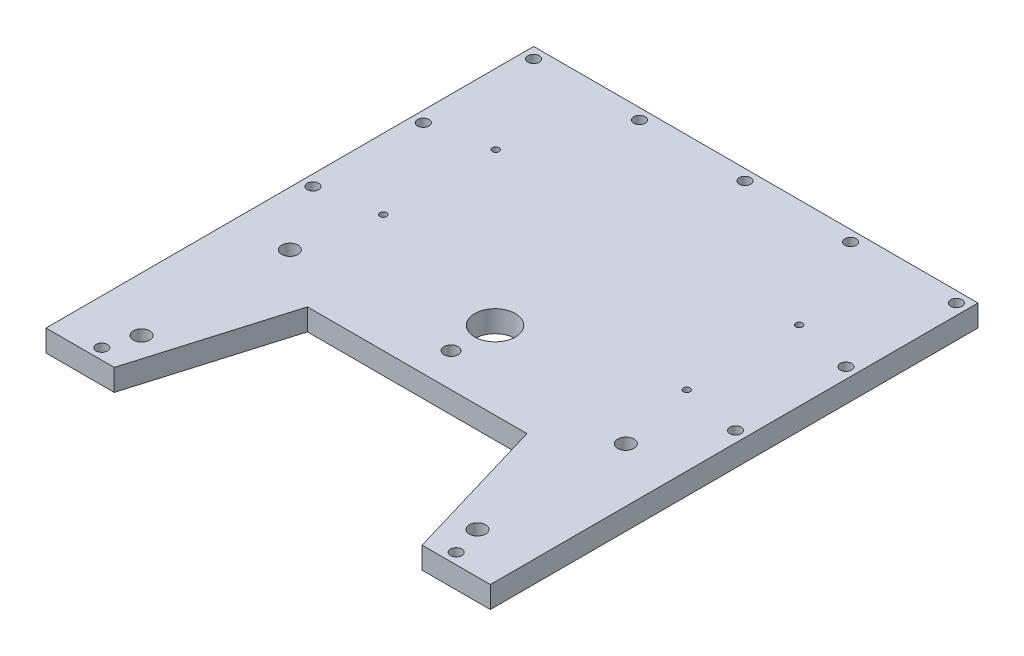
from build123d import *

# Parameters (mm, degrees)
BOSS_EXTRUDE3_DEPTH = 8
SKETCH3_R           = 2.1
CUT_EXTRUDE2_DEPTH  = 10
CUT_EXTRUDE3_REACH  = 10
SKETCH5_R           = 3
SKETCH5_R_2         = 7.5
SKETCH5_R_3         = 2.6
CUT_EXTRUDE4_REACH  = 10
SKETCH6_R           = 1.25


with BuildPart() as part:
    # Sketch1 → Boss-Extrude3 (new body)
    with BuildSketch(Plane(origin=(0, 0, 0), x_dir=(1, 0, 0), z_dir=(0, 1, 0))):
        Polygon((40.5, -35), (56.816666667, -90), (82, -90), (82, 90), (-82, 90), (-82, -90), (-56.816666667, -90), (-40.5, -35), align=None)
    extrude(amount=BOSS_EXTRUDE3_DEPTH)

    # Sketch3 → Cut-Extrude2 (cut)
    with BuildSketch(Plane(origin=(-73, 8, 0), x_dir=(0, 0, 1), z_dir=(0, 1, 0))):
        with Locations((-45.25, -5)):
            Circle(SKETCH3_R)
        with Locations((-86, -5)):
            Circle(SKETCH3_R)
        with Locations((-86, 34)):
            Circle(SKETCH3_R)
        with Locations((-86, 73)):
            Circle(SKETCH3_R)
        with Locations((-86, 112)):
            Circle(SKETCH3_R)
        with Locations((-86, 151)):
            Circle(SKETCH3_R)
        with Locations((-4.5, -5)):
            Circle(SKETCH3_R)
        with Locations((-4.5, 151)):
            Circle(SKETCH3_R)
        with Locations((-45.25, 151)):
            Circle(SKETCH3_R)
        with Locations((86, 7.59)):
            Circle(SKETCH3_R)
        with Locations((86, 138.41)):
            Circle(SKETCH3_R)
    extrude(amount=-CUT_EXTRUDE2_DEPTH, mode=Mode.SUBTRACT)

    # Sketch5 → Cut-Extrude3 (cut, up to next)
    with BuildSketch(Plane(origin=(0, 8, 0), x_dir=(1, 0, 0), z_dir=(0, 1, 0)), mode=Mode.PRIVATE) as cut_extrude3_sk1:
        with Locations((62, -74.75)):
            Circle(SKETCH5_R)
    cut_extrude3_tool1 = extrude(cut_extrude3_sk1.sketch, amount=-CUT_EXTRUDE3_REACH, mode=Mode.PRIVATE) & part.part
    add(cut_extrude3_tool1.solids().sort_by_distance((62, 8, 74.75))[0], mode=Mode.SUBTRACT)
    # Sketch5 → Cut-Extrude3 (cut, up to next)
    with BuildSketch(Plane(origin=(0, 8, 0), x_dir=(1, 0, 0), z_dir=(0, 1, 0)), mode=Mode.PRIVATE) as cut_extrude3_sk2:
        with Locations((62, -19.99)):
            Circle(SKETCH5_R)
    cut_extrude3_tool2 = extrude(cut_extrude3_sk2.sketch, amount=-CUT_EXTRUDE3_REACH, mode=Mode.PRIVATE) & part.part
    add(cut_extrude3_tool2.solids().sort_by_distance((62, 8, 19.99))[0], mode=Mode.SUBTRACT)
    # Sketch5 → Cut-Extrude3 (cut, up to next)
    with BuildSketch(Plane(origin=(0, 8, 0), x_dir=(1, 0, 0), z_dir=(0, 1, 0)), mode=Mode.PRIVATE) as cut_extrude3_sk3:
        with Locations((-62, -74.75)):
            Circle(SKETCH5_R)
    cut_extrude3_tool3 = extrude(cut_extrude3_sk3.sketch, amount=-CUT_EXTRUDE3_REACH, mode=Mode.PRIVATE) & part.part
    add(cut_extrude3_tool3.solids().sort_by_distance((-62, 8, 74.75))[0], mode=Mode.SUBTRACT)
    # Sketch5 → Cut-Extrude3 (cut, up to next)
    with BuildSketch(Plane(origin=(0, 8, 0), x_dir=(1, 0, 0), z_dir=(0, 1, 0)), mode=Mode.PRIVATE) as cut_extrude3_sk4:
        with Locations((-62, -19.99)):
            Circle(SKETCH5_R)
    cut_extrude3_tool4 = extrude(cut_extrude3_sk4.sketch, amount=-CUT_EXTRUDE3_REACH, mode=Mode.PRIVATE) & part.part
    add(cut_extrude3_tool4.solids().sort_by_distance((-62, 8, 19.99))[0], mode=Mode.SUBTRACT)
    # Sketch5 → Cut-Extrude3 (cut, up to next)
    with BuildSketch(Plane(origin=(0, 8, 0), x_dir=(1, 0, 0), z_dir=(0, 1, 0)), mode=Mode.PRIVATE) as cut_extrude3_sk5:
        with Locations((0, -6.25)):
            Circle(SKETCH5_R_2)
    cut_extrude3_tool5 = extrude(cut_extrude3_sk5.sketch, amount=-CUT_EXTRUDE3_REACH, mode=Mode.PRIVATE) & part.part
    add(cut_extrude3_tool5.solids().sort_by_distance((0, 8, 6.25))[0], mode=Mode.SUBTRACT)
    # Sketch5 → Cut-Extrude3 (cut, up to next)
    with BuildSketch(Plane(origin=(0, 8, 0), x_dir=(1, 0, 0), z_dir=(0, 1, 0)), mode=Mode.PRIVATE) as cut_extrude3_sk6:
        with Locations((0, -22.5)):
            Circle(SKETCH5_R_3)
    cut_extrude3_tool6 = extrude(cut_extrude3_sk6.sketch, amount=-CUT_EXTRUDE3_REACH, mode=Mode.PRIVATE) & part.part
    add(cut_extrude3_tool6.solids().sort_by_distance((0, 8, 22.5))[0], mode=Mode.SUBTRACT)

    # Sketch6 → Cut-Extrude4 (cut, up to next)
    with BuildSketch(Plane(origin=(0, 8, 0), x_dir=(1, 0, 0), z_dir=(0, 1, 0)), mode=Mode.PRIVATE) as cut_extrude4_sk1:
        with Locations((-56, 8.5)):
            Circle(SKETCH6_R)
    cut_extrude4_tool1 = extrude(cut_extrude4_sk1.sketch, amount=-CUT_EXTRUDE4_REACH, mode=Mode.PRIVATE) & part.part
    add(cut_extrude4_tool1.solids().sort_by_distance((-56, 8, -8.5))[0], mode=Mode.SUBTRACT)
    # Sketch6 → Cut-Extrude4 (cut, up to next)
    with BuildSketch(Plane(origin=(0, 8, 0), x_dir=(1, 0, 0), z_dir=(0, 1, 0)), mode=Mode.PRIVATE) as cut_extrude4_sk2:
        with Locations((-56, 50)):
            Circle(SKETCH6_R)
    cut_extrude4_tool2 = extrude(cut_extrude4_sk2.sketch, amount=-CUT_EXTRUDE4_REACH, mode=Mode.PRIVATE) & part.part
    add(cut_extrude4_tool2.solids().sort_by_distance((-56, 8, -50))[0], mode=Mode.SUBTRACT)
    # Sketch6 → Cut-Extrude4 (cut, up to next)
    with BuildSketch(Plane(origin=(0, 8, 0), x_dir=(1, 0, 0), z_dir=(0, 1, 0)), mode=Mode.PRIVATE) as cut_extrude4_sk3:
        with Locations((56, 50)):
            Circle(SKETCH6_R)
    cut_extrude4_tool3 = extrude(cut_extrude4_sk3.sketch, amount=-CUT_EXTRUDE4_REACH, mode=Mode.PRIVATE) & part.part
    add(cut_extrude4_tool3.solids().sort_by_distance((56, 8, -50))[0], mode=Mode.SUBTRACT)
    # Sketch6 → Cut-Extrude4 (cut, up to next)
    with BuildSketch(Plane(origin=(0, 8, 0), x_dir=(1, 0, 0), z_dir=(0, 1, 0)), mode=Mode.PRIVATE) as cut_extrude4_sk4:
        with Locations((56, 8.5)):
            Circle(SKETCH6_R)
    cut_extrude4_tool4 = extrude(cut_extrude4_sk4.sketch, amount=-CUT_EXTRUDE4_REACH, mode=Mode.PRIVATE) & part.part
    add(cut_extrude4_tool4.solids().sort_by_distance((56, 8, -8.5))[0], mode=Mode.SUBTRACT)


solid = part.part
